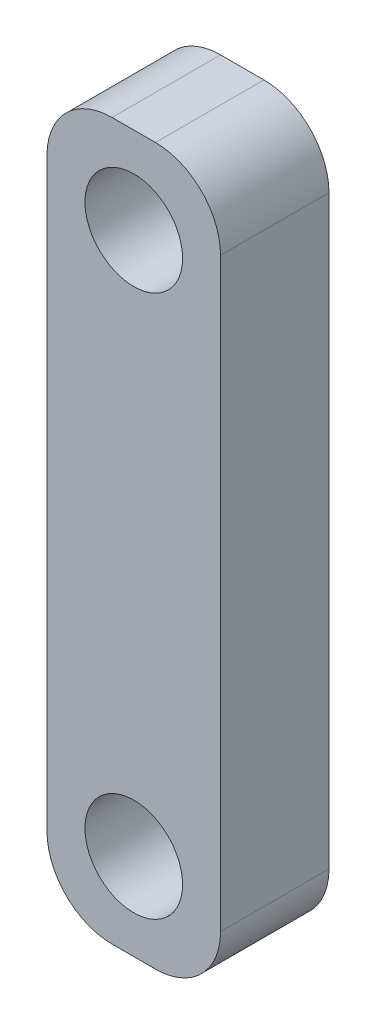
from build123d import *

# Parameters (mm, degrees)
SKETCH1_W           = 8
SKETCH1_H           = 33
SKETCH1_R           = 2.25
BOSS_EXTRUDE1_DEPTH = 5
FILLET1_R           = 3


with BuildPart() as part:
    # Sketch1 → Boss-Extrude1 (new body)
    with BuildSketch(Plane.XY):
        with Locations((4, -16.5)):
            Rectangle(SKETCH1_W, SKETCH1_H)
        with Locations((4, -29)):
            Circle(SKETCH1_R, mode=Mode.SUBTRACT)
        with Locations((4, -4)):
            Circle(SKETCH1_R, mode=Mode.SUBTRACT)
    extrude(amount=BOSS_EXTRUDE1_DEPTH)

    # Fillet1
    fillet1_edges = [part.edges().sort_by_distance(p)[0] for p in [
        (0, 0, 2.5),
        (8, 0, 2.5),
        (8, -33, 2.5),
        (0, -33, 2.5),
    ]]
    fillet(fillet1_edges, radius=FILLET1_R)


solid = part.part
